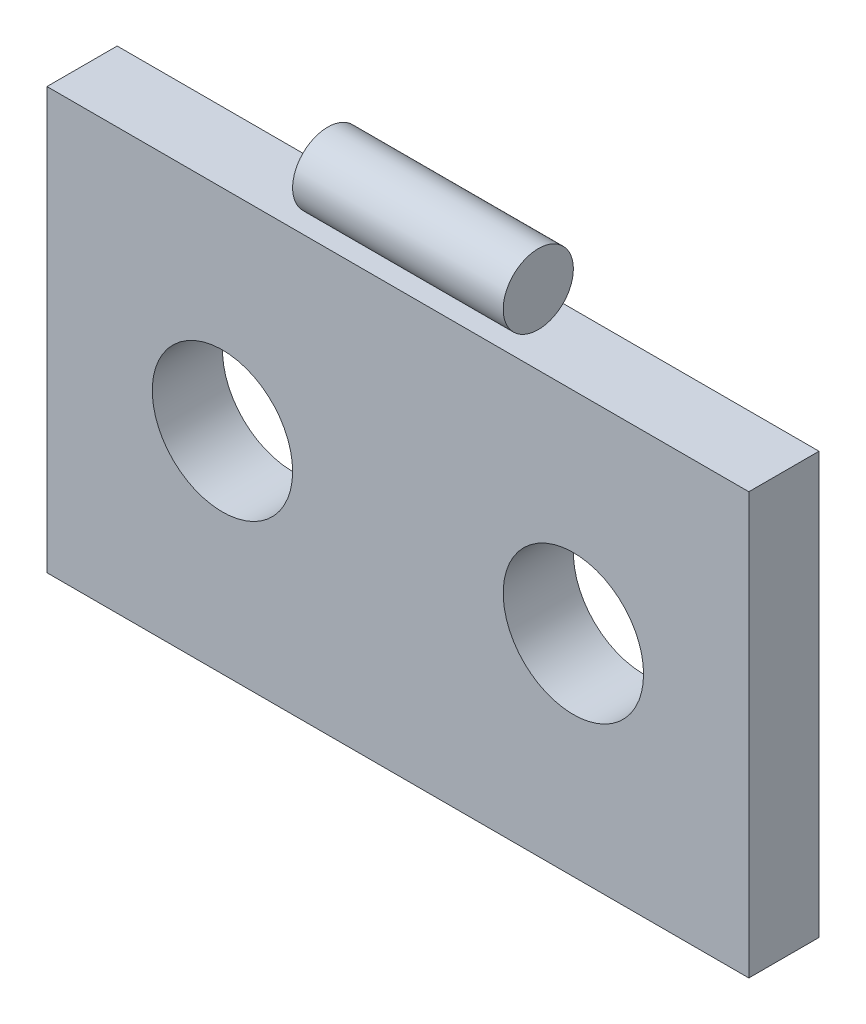
from build123d import *

# Parameters (mm, degrees)
ESQUISSE1_W             = 50
ESQUISSE1_H             = 30
BOSS_EXTRU_1_DEPTH      = 5
ESQUISSE2_R             = 5
ENL_V_MAT_EXTRU_1_DEPTH = 6
ESQUISSE3_R             = 2.5
BOSS_EXTRU_2_DEPTH      = 50
ESQUISSE5_W             = 17.5
ESQUISSE5_H             = 5
ENL_V_MAT_EXTRU_6_DEPTH = 6


with BuildPart() as part:
    # Esquisse1 → Boss.-Extru.1 (new body)
    with BuildSketch(Plane.XY):
        with Locations((25, 15)):
            Rectangle(ESQUISSE1_W, ESQUISSE1_H)
    extrude(amount=BOSS_EXTRU_1_DEPTH)

    # Esquisse2 → Enlèv. mat.-Extru.1 (cut, through all)
    with BuildSketch(Plane.XY.offset(5)):
        with Locations((12.5, 15)):
            Circle(ESQUISSE2_R)
        with Locations((37.5, 15)):
            Circle(ESQUISSE2_R)
    extrude(amount=-ENL_V_MAT_EXTRU_1_DEPTH, mode=Mode.SUBTRACT)


with BuildPart() as body_2:
    # Esquisse3 → Boss.-Extru.2 (new body)
    with BuildSketch(Plane(origin=(50, 0, 0), x_dir=(0, 0, -1), z_dir=(1, 0, 0))):
        with Locations((-2.5, 32.5)):
            Circle(ESQUISSE3_R)
    extrude(amount=-BOSS_EXTRU_2_DEPTH)

    # Esquisse5 → Enlèv. mat.-Extru.6 (cut, through all)
    with BuildSketch(Plane.XY.offset(5)):
        with Locations((8.75, 32.5)):
            Rectangle(ESQUISSE5_W, ESQUISSE5_H)
        with Locations((41.25, 32.5)):
            Rectangle(ESQUISSE5_W, ESQUISSE5_H)
    extrude(amount=-ENL_V_MAT_EXTRU_6_DEPTH, mode=Mode.SUBTRACT)


solid = Compound([part.part, body_2.part])
